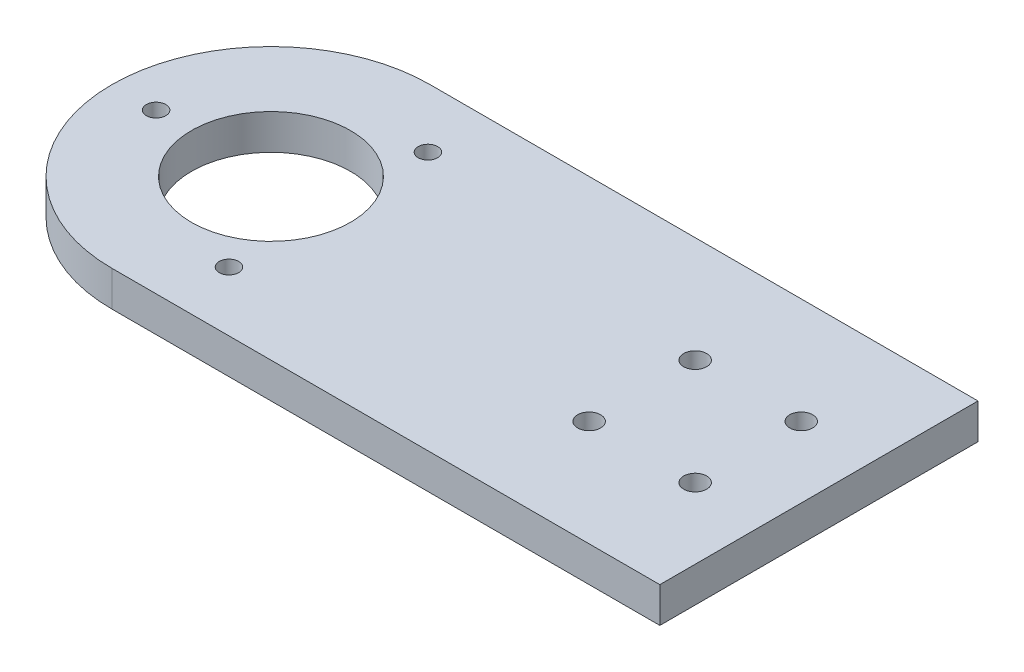
from build123d import *

# Parameters (mm, degrees)
BOSS_EXTRUDE1_DEPTH = 10
SKETCH2_R           = 2.75
SKETCH2_R_2         = 22.5
CUT_EXTRUDE1_DEPTH  = 11
SKETCH3_R           = 3.25
CUT_EXTRUDE2_DEPTH  = 11


with BuildPart() as part:
    # Sketch1 → Boss-Extrude1 (new body)
    with BuildSketch(Plane(origin=(0, 0, 0), x_dir=(1, 0, 0), z_dir=(0, 1, 0))):
        with BuildLine():
            Line((100, 45), (-55, 45))
            ThreePointArc((-55, 45), (-100, 0), (-55, -45))
            Line((-55, -45), (100, -45))
            Line((100, -45), (100, 45))
        make_face()
    extrude(amount=BOSS_EXTRUDE1_DEPTH)

    # Sketch2 → Cut-Extrude1 (cut, through all)
    with BuildSketch(Plane(origin=(0, 10, 0), x_dir=(1, 0, 0), z_dir=(0, 1, 0))):
        with Locations((-87.5, 0)):
            Circle(SKETCH2_R)
        with Locations((-38.75, 28.145825623)):
            Circle(SKETCH2_R)
        with Locations((-38.75, -28.145825623)):
            Circle(SKETCH2_R)
        with Locations((-55, 0)):
            Circle(SKETCH2_R_2)
    extrude(amount=-CUT_EXTRUDE1_DEPTH, mode=Mode.SUBTRACT)

    # Sketch3 → Cut-Extrude2 (cut, through all)
    with BuildSketch(Plane(origin=(0, 10, 0), x_dir=(1, 0, 0), z_dir=(0, 1, 0))):
        with Locations((80, 15)):
            Circle(SKETCH3_R)
        with Locations((50, 15)):
            Circle(SKETCH3_R)
        with Locations((50, -15)):
            Circle(SKETCH3_R)
        with Locations((80, -15)):
            Circle(SKETCH3_R)
    extrude(amount=-CUT_EXTRUDE2_DEPTH, mode=Mode.SUBTRACT)


solid = part.part
